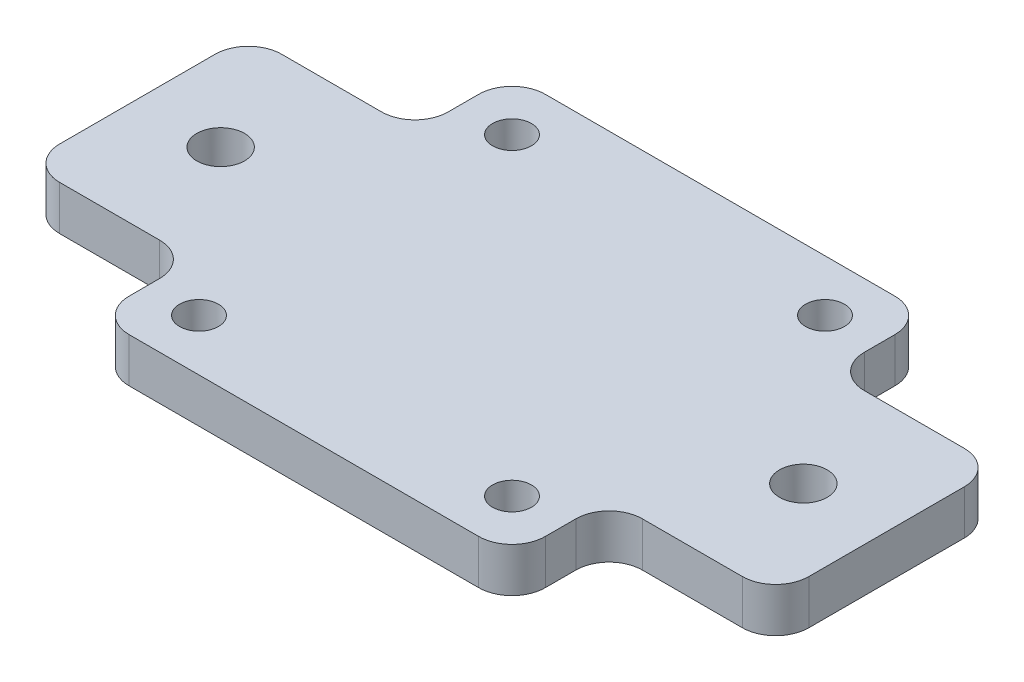
from build123d import *

# Parameters (mm, degrees)
SKETCH1_W               = 37.5
SKETCH1_H               = 37.5
BOSS_EXTRUDE1_DEPTH     = 4
FILLET1_R               = 3
SKETCH5_R               = 1.75
CUT_EXTRUDE2_DEPTH      = 1
CUT_EXTRUDE2_DEPTH_BACK = 5
SKETCH6_W               = 67.5
SKETCH6_H               = 20
BOSS_EXTRUDE2_DEPTH     = 4
FILLET2_R               = 3
SKETCH7_R               = 2.15
CUT_EXTRUDE3_DEPTH      = 1
CUT_EXTRUDE3_DEPTH_BACK = 5


with BuildPart() as part:
    # Sketch1 → Boss-Extrude1 (new body)
    with BuildSketch(Plane(origin=(0, 0, 0), x_dir=(1, 0, 0), z_dir=(0, 1, 0))):
        Rectangle(SKETCH1_W, SKETCH1_H)
    extrude(amount=BOSS_EXTRUDE1_DEPTH)

    # Fillet1
    fillet1_edges = [part.edges().sort_by_distance(p)[0] for p in [
        (18.75, 2, 18.75),
        (-18.75, 2, 18.75),
        (-18.75, 2, -18.75),
        (18.75, 2, -18.75),
    ]]
    fillet(fillet1_edges, radius=FILLET1_R)

    # Sketch5 → Cut-Extrude2 (cut, two sides)
    with BuildSketch(Plane(origin=(0, 4, 0), x_dir=(1, 0, 0), z_dir=(0, 1, 0))) as cut_extrude2_sk:
        with Locations((-14.1, 14.1)):
            Circle(SKETCH5_R)
        with Locations((14.1, 14.1)):
            Circle(SKETCH5_R)
        with Locations((14.1, -14.1)):
            Circle(SKETCH5_R)
        with Locations((-14.1, -14.1)):
            Circle(SKETCH5_R)
    extrude(amount=CUT_EXTRUDE2_DEPTH, mode=Mode.SUBTRACT)
    extrude(cut_extrude2_sk.sketch, amount=-CUT_EXTRUDE2_DEPTH_BACK, mode=Mode.SUBTRACT)

    # Sketch6 → Boss-Extrude2 (add)
    with BuildSketch(Plane.XZ):
        Rectangle(SKETCH6_W, SKETCH6_H)
    extrude(amount=-BOSS_EXTRUDE2_DEPTH)

    # Fillet2
    fillet2_edges = [part.edges().sort_by_distance(p)[0] for p in [
        (33.75, 2, -10),
        (18.75, 2, 10),
        (-18.75, 2, 10),
        (-33.75, 2, 10),
        (-33.75, 2, -10),
        (18.75, 2, -10),
        (-18.75, 2, -10),
        (33.75, 2, 10),
    ]]
    fillet(fillet2_edges, radius=FILLET2_R)

    # Sketch7 → Cut-Extrude3 (cut, two sides)
    with BuildSketch(Plane(origin=(0, 4, 0), x_dir=(1, 0, 0), z_dir=(0, 1, 0))) as cut_extrude3_sk:
        with Locations((-26.25, 0)):
            Circle(SKETCH7_R)
        with Locations((26.25, 0)):
            Circle(SKETCH7_R)
    extrude(amount=CUT_EXTRUDE3_DEPTH, mode=Mode.SUBTRACT)
    extrude(cut_extrude3_sk.sketch, amount=-CUT_EXTRUDE3_DEPTH_BACK, mode=Mode.SUBTRACT)


solid = part.part
